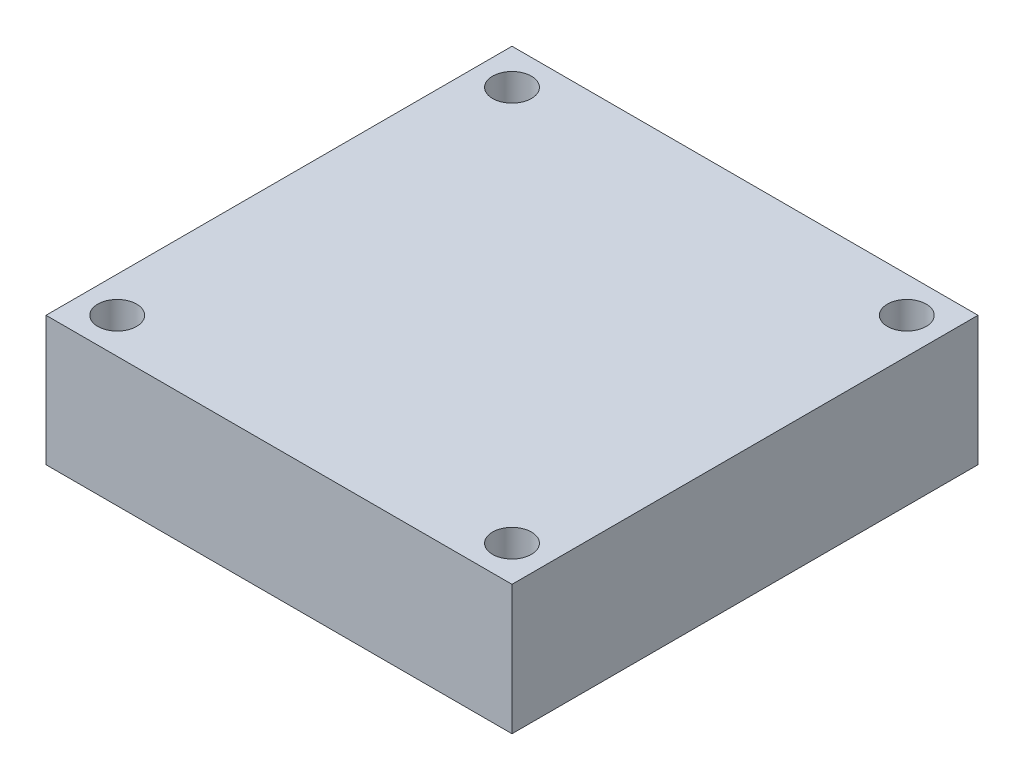
from build123d import *

# Parameters (mm, degrees)
SKETCH1_W           = 36
SKETCH1_H           = 36
BOSS_EXTRUDE1_DEPTH = 10
SKETCH2_R           = 1.5
CUT_EXTRUDE1_DEPTH  = 10


with BuildPart() as part:
    # Sketch1 → Boss-Extrude1 (new body)
    with BuildSketch(Plane(origin=(0, 0, 0), x_dir=(1, 0, 0), z_dir=(0, 1, 0))):
        Rectangle(SKETCH1_W, SKETCH1_H)
    extrude(amount=BOSS_EXTRUDE1_DEPTH)

    # Sketch2 → Cut-Extrude1 (cut)
    with BuildSketch(Plane(origin=(0, 10, 0), x_dir=(1, 0, 0), z_dir=(0, 1, 0))):
        with Locations((-15.25, 15.25)):
            Circle(SKETCH2_R)
        with Locations((15.25, 15.25)):
            Circle(SKETCH2_R)
        with Locations((15.25, -15.25)):
            Circle(SKETCH2_R)
        with Locations((-15.25, -15.25)):
            Circle(SKETCH2_R)
    extrude(amount=-CUT_EXTRUDE1_DEPTH, mode=Mode.SUBTRACT)


solid = part.part
